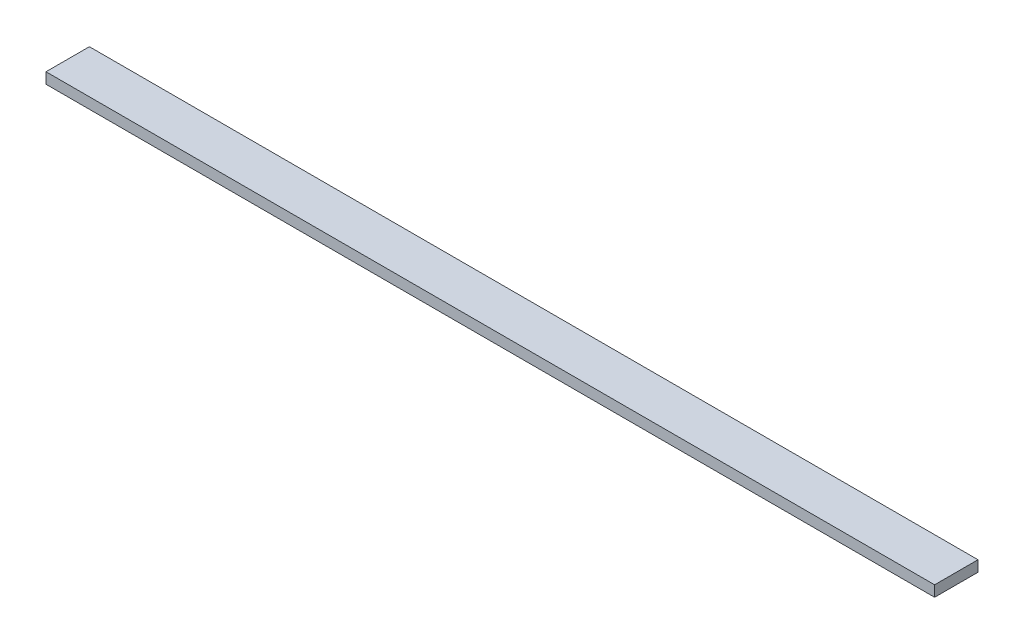
from build123d import *

# Parameters (mm, degrees)
SKETCH1_W           = 260.096
SKETCH1_H           = 12.7
BOSS_EXTRUDE1_DEPTH = 3.175


with BuildPart() as part:
    # Sketch1 → Boss-Extrude1 (new body)
    with BuildSketch(Plane(origin=(0, 0, 0), x_dir=(1, 0, 0), z_dir=(0, 1, 0))):
        with Locations((130.048, 6.35)):
            Rectangle(SKETCH1_W, SKETCH1_H)
    extrude(amount=BOSS_EXTRUDE1_DEPTH)


solid = part.part
